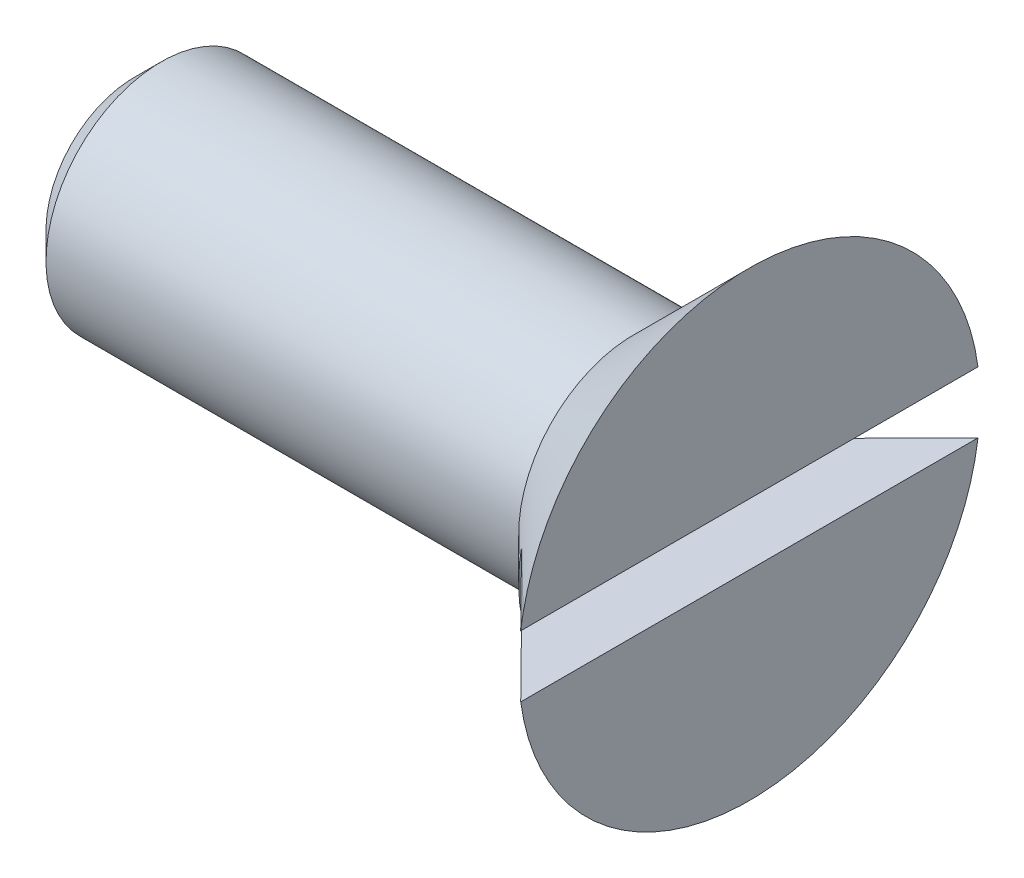
from build123d import *

# Parameters (mm, degrees)
SKETCH2_W          = 1.9
SKETCH2_H          = 1.6
CUT_EXTRUDE1_DEPTH = 50


with BuildPart() as part:
    # Sketch1 → Revolve1 (revolve)
    with BuildSketch(Plane.XY):
        Polygon((6.382934587, 0), (6.382934587, 6), (3.382934587, 3), (-8.909958632, 3), (-9.617065413, 2.292893219), (-9.617065413, 0), align=None)
    revolve(axis=Axis((-31.290557053, 0, 0), (1, 0, 0)))

    # Sketch2 → Cut-Extrude1 (cut, symmetric)
    with BuildSketch(Plane.XY):
        with Locations((5.432934587, 0)):
            Rectangle(SKETCH2_W, SKETCH2_H)
    extrude(amount=CUT_EXTRUDE1_DEPTH, both=True, mode=Mode.SUBTRACT)


solid = part.part
